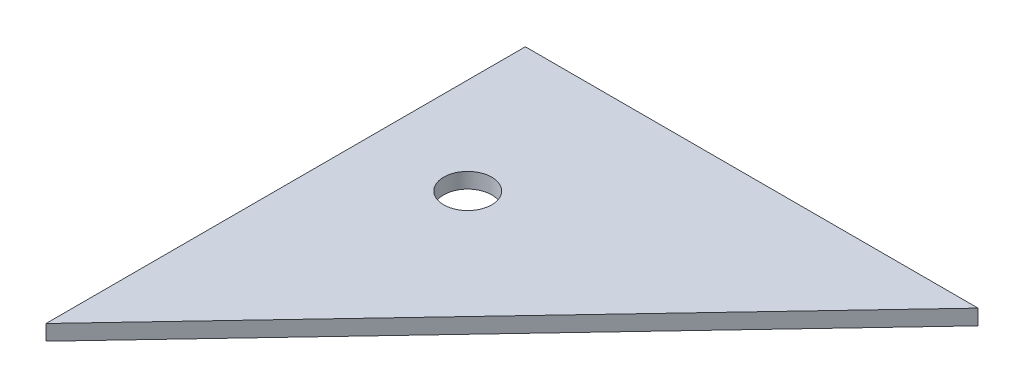
from build123d import *

# Parameters (mm, degrees)
SKETCH1_R           = 3.96875
BOSS_EXTRUDE1_DEPTH = 2.54


with BuildPart() as part:
    # Sketch1 → Boss-Extrude1 (new body)
    with BuildSketch(Plane(origin=(0, 0, 0), x_dir=(1, 0, 0), z_dir=(0, 1, 0))):
        Polygon((0, 0), (0, 79.205790537), (74.7965167, 79.205790537), align=None)
        with Locations((15.875, 53.805790537)):
            Circle(SKETCH1_R, mode=Mode.SUBTRACT)
    extrude(amount=BOSS_EXTRUDE1_DEPTH)


solid = part.part
